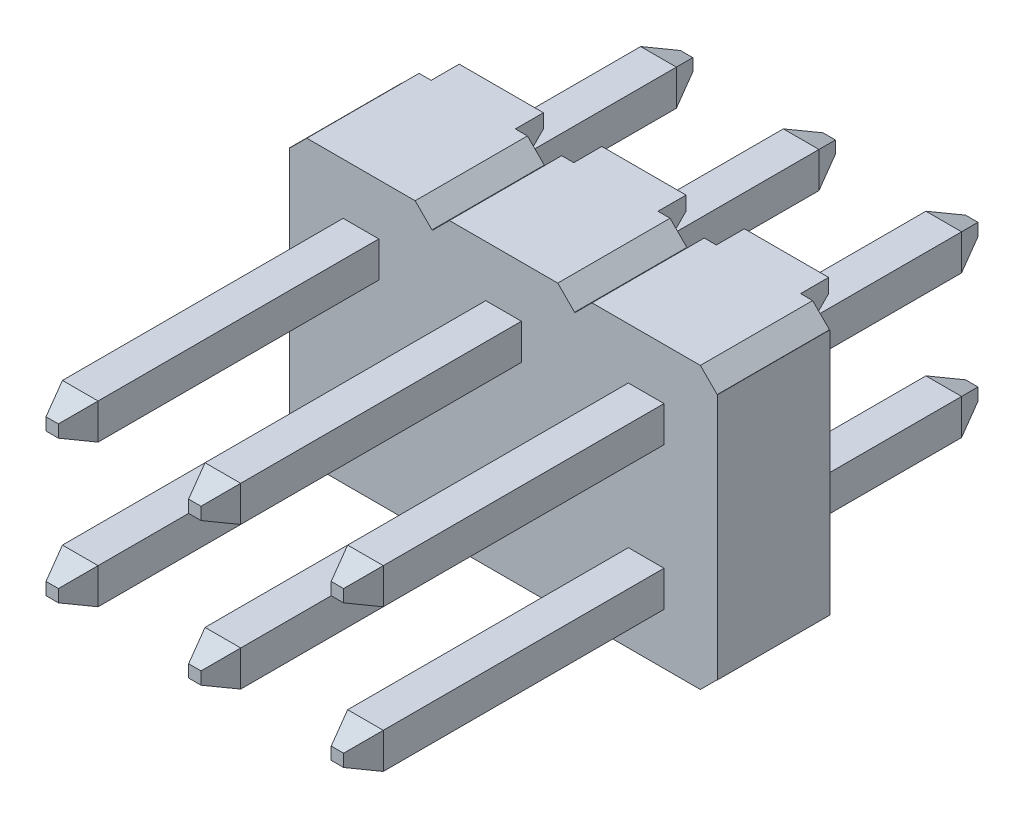
from build123d import *

# Parameters (mm, degrees)
SKETCH1_W              = 7.62
SKETCH1_H              = 5
BOSS_EXTRUDE1_DEPTH    = 2
SKETCH2_W              = 0.305
SKETCH2_H              = 0.3
CUT_EXTRUDE1_DEPTH     = 3
CUT_EXTRUDE2_DEPTH     = 3
CUT_EXTRUDE3_DEPTH     = 3
SKETCH5_W              = 0.305
SKETCH5_H              = 0.3
CUT_EXTRUDE4_DEPTH     = 2
SKETCH6_W              = 0.305
SKETCH6_H              = 0.3
CUT_EXTRUDE5_DEPTH     = 3
CUT_EXTRUDE6_DEPTH     = 3
CUT_EXTRUDE7_DEPTH     = 3
SKETCH9_W              = 0.305
SKETCH9_H              = 0.3
CUT_EXTRUDE8_DEPTH     = 2
SKETCH10_W             = 0.635
SKETCH10_H             = 0.635
BOSS_EXTRUDE2_DEPTH    = 3.8
SKETCH11_W             = 0.635
SKETCH11_H             = 0.635
BOSS_EXTRUDE3_DEPTH    = 3.8
SKETCH12_W             = 0.635
SKETCH12_H             = 0.635
BOSS_EXTRUDE4_DEPTH    = 3.8
SKETCH13_W             = 0.635
SKETCH13_H             = 0.635
BOSS_EXTRUDE5_DEPTH    = 3.8
SKETCH14_W             = 0.635
SKETCH14_H             = 0.635
BOSS_EXTRUDE6_DEPTH    = 3.8
SKETCH15_W             = 1.5
SKETCH15_H             = 0.75
BOSS_EXTRUDE7_DEPTH    = 0.5
SKETCH16_W             = 1.5
SKETCH16_H             = 0.75
BOSS_EXTRUDE8_DEPTH    = 0.5
SKETCH17_W             = 1.5
SKETCH17_H             = 0.75
BOSS_EXTRUDE9_DEPTH    = 0.5
SKETCH18_W             = 1.5
SKETCH18_H             = 0.75
BOSS_EXTRUDE10_DEPTH   = 0.5
SKETCH19_W             = 1.5
SKETCH19_H             = 0.75
BOSS_EXTRUDE11_DEPTH   = 0.5
SKETCH20_W             = 1.5
SKETCH20_H             = 0.75
BOSS_EXTRUDE12_DEPTH   = 0.5
SKETCH21_W             = 0.635
SKETCH21_H             = 0.635
BOSS_EXTRUDE13_DEPTH   = 3.8
SKETCH22_W             = 0.635
SKETCH22_H             = 0.635
BOSS_EXTRUDE14_DEPTH   = 5.5
SKETCH23_W             = 0.635
SKETCH23_H             = 0.635
BOSS_EXTRUDE15_DEPTH   = 5.5
SKETCH24_W             = 0.635
SKETCH24_H             = 0.635
BOSS_EXTRUDE16_DEPTH   = 5.5
SKETCH25_W             = 0.635
SKETCH25_H             = 0.635
BOSS_EXTRUDE17_DEPTH   = 5.5
SKETCH26_W             = 0.635
SKETCH26_H             = 0.635
BOSS_EXTRUDE18_DEPTH   = 5.5
SKETCH27_W             = 0.635
SKETCH27_H             = 0.635
BOSS_EXTRUDE19_DEPTH   = 5.5
DRAFT1_ANGLE           = 45
DRAFT2_ANGLE           = 45
DRAFT3_ANGLE           = 45
DRAFT4_ANGLE           = 45
DRAFT5_ANGLE           = 45
CHAMFER1_SIZE          = 0.007071068
CHAMFER2_SIZE          = 0.207106781
CHAMFER2_SIZE2         = 0.5
CHAMFER2_PART_2_SIZE   = 0.207106781
CHAMFER2_PART_2_SIZE2  = 0.5
CHAMFER2_PART_3_SIZE   = 0.207106781
CHAMFER2_PART_3_SIZE2  = 0.5
CHAMFER2_PART_4_SIZE   = 0.207106781
CHAMFER2_PART_4_SIZE2  = 0.5
CHAMFER2_PART_5_SIZE   = 0.207106781
CHAMFER2_PART_5_SIZE2  = 0.5
CHAMFER2_PART_6_SIZE   = 0.207106781
CHAMFER2_PART_6_SIZE2  = 0.5
CHAMFER2_PART_7_SIZE   = 0.207106781
CHAMFER2_PART_7_SIZE2  = 0.5
CHAMFER2_PART_8_SIZE   = 0.207106781
CHAMFER2_PART_8_SIZE2  = 0.5
CHAMFER2_PART_9_SIZE   = 0.207106781
CHAMFER2_PART_9_SIZE2  = 0.5
CHAMFER2_PART_10_SIZE  = 0.207106781
CHAMFER2_PART_10_SIZE2 = 0.5
CHAMFER2_PART_11_SIZE  = 0.207106781
CHAMFER2_PART_11_SIZE2 = 0.5
CHAMFER2_PART_12_SIZE  = 0.207106781
CHAMFER2_PART_12_SIZE2 = 0.5


with BuildPart() as part:
    # Sketch1 → Boss-Extrude1 (new body)
    with BuildSketch(Plane(origin=(0, 0, 0), x_dir=(-1, 0, 0), z_dir=(0, 0, -1))):
        with Locations((-3.81, 2.5)):
            Rectangle(SKETCH1_W, SKETCH1_H)
    extrude(amount=-BOSS_EXTRUDE1_DEPTH)

    # Sketch2 → Cut-Extrude1 (cut, through all)
    with BuildSketch(Plane.XY.offset(2)):
        with Locations((7.4675, 0.15)):
            Rectangle(SKETCH2_W, SKETCH2_H)
    extrude(amount=-CUT_EXTRUDE1_DEPTH, mode=Mode.SUBTRACT)

    # Sketch3 → Cut-Extrude2 (cut, through all)
    with BuildSketch(Plane.XY.offset(2)):
        Polygon((4.775, 0), (5.385, 0), (5.385, 0.61), align=None)
    extrude(amount=-CUT_EXTRUDE2_DEPTH, mode=Mode.SUBTRACT)

    # Sketch4 → Cut-Extrude3 (cut, through all)
    with BuildSketch(Plane.XY.offset(2)):
        Polygon((2.235, 0), (2.845, 0), (2.235, 0.61), align=None)
    extrude(amount=-CUT_EXTRUDE3_DEPTH, mode=Mode.SUBTRACT)

    # Sketch5 → Cut-Extrude4 (cut)
    with BuildSketch(Plane.XY.offset(2)):
        with Locations((0.1525, 0.15)):
            Rectangle(SKETCH5_W, SKETCH5_H)
    extrude(amount=-CUT_EXTRUDE4_DEPTH, mode=Mode.SUBTRACT)

    # Sketch6 → Cut-Extrude5 (cut, through all)
    with BuildSketch(Plane.XY.offset(2)):
        with Locations((0.1525, 4.85)):
            Rectangle(SKETCH6_W, SKETCH6_H)
    extrude(amount=-CUT_EXTRUDE5_DEPTH, mode=Mode.SUBTRACT)

    # Sketch7 → Cut-Extrude6 (cut, through all)
    with BuildSketch(Plane.XY.offset(2)):
        Polygon((2.845, 5), (2.235, 5), (2.235, 4.39), align=None)
    extrude(amount=-CUT_EXTRUDE6_DEPTH, mode=Mode.SUBTRACT)

    # Sketch8 → Cut-Extrude7 (cut, through all)
    with BuildSketch(Plane.XY.offset(2)):
        Polygon((5.385, 5), (4.775, 5), (5.385, 4.39), align=None)
    extrude(amount=-CUT_EXTRUDE7_DEPTH, mode=Mode.SUBTRACT)

    # Sketch9 → Cut-Extrude8 (cut)
    with BuildSketch(Plane.XY.offset(2)):
        with Locations((7.4675, 4.85)):
            Rectangle(SKETCH9_W, SKETCH9_H)
    extrude(amount=-CUT_EXTRUDE8_DEPTH, mode=Mode.SUBTRACT)

    # Sketch10 → Boss-Extrude2 (add)
    with BuildSketch(Plane(origin=(0, 0, 0), x_dir=(-1, 0, 0), z_dir=(0, 0, -1))):
        with Locations((-6.35, 3.77)):
            Rectangle(SKETCH10_W, SKETCH10_H)
    extrude(amount=BOSS_EXTRUDE2_DEPTH)

    # Sketch11 → Boss-Extrude3 (add)
    with BuildSketch(Plane(origin=(0, 0, 0), x_dir=(-1, 0, 0), z_dir=(0, 0, -1))):
        with Locations((-6.35, 1.23)):
            Rectangle(SKETCH11_W, SKETCH11_H)
    extrude(amount=BOSS_EXTRUDE3_DEPTH)

    # Sketch12 → Boss-Extrude4 (add)
    with BuildSketch(Plane(origin=(0, 0, 0), x_dir=(-1, 0, 0), z_dir=(0, 0, -1))):
        with Locations((-3.81, 3.77)):
            Rectangle(SKETCH12_W, SKETCH12_H)
    extrude(amount=BOSS_EXTRUDE4_DEPTH)

    # Sketch13 → Boss-Extrude5 (add)
    with BuildSketch(Plane(origin=(0, 0, 0), x_dir=(-1, 0, 0), z_dir=(0, 0, -1))):
        with Locations((-3.81, 1.23)):
            Rectangle(SKETCH13_W, SKETCH13_H)
    extrude(amount=BOSS_EXTRUDE5_DEPTH)

    # Sketch14 → Boss-Extrude6 (add)
    with BuildSketch(Plane(origin=(0, 0, 0), x_dir=(-1, 0, 0), z_dir=(0, 0, -1))):
        with Locations((-1.27, 3.77)):
            Rectangle(SKETCH14_W, SKETCH14_H)
    extrude(amount=BOSS_EXTRUDE6_DEPTH)

    # Sketch15 → Boss-Extrude7 (add)
    with BuildSketch(Plane(origin=(0, 0, 0), x_dir=(-1, 0, 0), z_dir=(0, 0, -1))):
        with Locations((-6.35, 0.375)):
            Rectangle(SKETCH15_W, SKETCH15_H)
    extrude(amount=BOSS_EXTRUDE7_DEPTH)

    # Sketch16 → Boss-Extrude8 (add)
    with BuildSketch(Plane(origin=(0, 0, 0), x_dir=(-1, 0, 0), z_dir=(0, 0, -1))):
        with Locations((-3.81, 0.375)):
            Rectangle(SKETCH16_W, SKETCH16_H)
    extrude(amount=BOSS_EXTRUDE8_DEPTH)

    # Sketch17 → Boss-Extrude9 (add)
    with BuildSketch(Plane(origin=(0, 0, 0), x_dir=(-1, 0, 0), z_dir=(0, 0, -1))):
        with Locations((-1.27, 0.375)):
            Rectangle(SKETCH17_W, SKETCH17_H)
    extrude(amount=BOSS_EXTRUDE9_DEPTH)

    # Sketch18 → Boss-Extrude10 (add)
    with BuildSketch(Plane(origin=(0, 0, 0), x_dir=(-1, 0, 0), z_dir=(0, 0, -1))):
        with Locations((-1.27, 4.625)):
            Rectangle(SKETCH18_W, SKETCH18_H)
    extrude(amount=BOSS_EXTRUDE10_DEPTH)

    # Sketch19 → Boss-Extrude11 (add)
    with BuildSketch(Plane(origin=(0, 0, 0), x_dir=(-1, 0, 0), z_dir=(0, 0, -1))):
        with Locations((-3.81, 4.625)):
            Rectangle(SKETCH19_W, SKETCH19_H)
    extrude(amount=BOSS_EXTRUDE11_DEPTH)

    # Sketch20 → Boss-Extrude12 (add)
    with BuildSketch(Plane(origin=(0, 0, 0), x_dir=(-1, 0, 0), z_dir=(0, 0, -1))):
        with Locations((-6.35, 4.625)):
            Rectangle(SKETCH20_W, SKETCH20_H)
    extrude(amount=BOSS_EXTRUDE12_DEPTH)

    # Sketch21 → Boss-Extrude13 (add)
    with BuildSketch(Plane(origin=(0, 0, 0), x_dir=(-1, 0, 0), z_dir=(0, 0, -1))):
        with Locations((-1.27, 1.23)):
            Rectangle(SKETCH21_W, SKETCH21_H)
    extrude(amount=BOSS_EXTRUDE13_DEPTH)

    # Sketch22 → Boss-Extrude14 (add)
    with BuildSketch(Plane.XY.offset(2)):
        with Locations((6.35, 3.77)):
            Rectangle(SKETCH22_W, SKETCH22_H)
    extrude(amount=BOSS_EXTRUDE14_DEPTH)

    # Sketch23 → Boss-Extrude15 (add)
    with BuildSketch(Plane.XY.offset(2)):
        with Locations((6.35, 1.23)):
            Rectangle(SKETCH23_W, SKETCH23_H)
    extrude(amount=BOSS_EXTRUDE15_DEPTH)

    # Sketch24 → Boss-Extrude16 (add)
    with BuildSketch(Plane.XY.offset(2)):
        with Locations((3.81, 3.77)):
            Rectangle(SKETCH24_W, SKETCH24_H)
    extrude(amount=BOSS_EXTRUDE16_DEPTH)

    # Sketch25 → Boss-Extrude17 (add)
    with BuildSketch(Plane.XY.offset(2)):
        with Locations((3.81, 1.23)):
            Rectangle(SKETCH25_W, SKETCH25_H)
    extrude(amount=BOSS_EXTRUDE17_DEPTH)

    # Sketch26 → Boss-Extrude18 (add)
    with BuildSketch(Plane.XY.offset(2)):
        with Locations((1.27, 3.77)):
            Rectangle(SKETCH26_W, SKETCH26_H)
    extrude(amount=BOSS_EXTRUDE18_DEPTH)

    # Sketch27 → Boss-Extrude19 (add)
    with BuildSketch(Plane.XY.offset(2)):
        with Locations((1.27, 1.23)):
            Rectangle(SKETCH27_W, SKETCH27_H)
    extrude(amount=BOSS_EXTRUDE19_DEPTH)

    # Draft1
    draft1_faces = [part.faces().sort_by_distance(p)[0] for p in [
        (5.385, 0.305, 1),
        (7.315, 0.15, 1),
    ]]
    draft(draft1_faces, Plane(origin=(7.62, 0, 2), x_dir=(0, 0, -1), z_dir=(0, -1, 0)), DRAFT1_ANGLE)

    # Draft2
    draft2_faces = [part.faces().sort_by_distance(p)[0] for p in [
        (0.305, 0.15, 1),
        (2.235, 0.305, 1),
    ]]
    draft(draft2_faces, Plane(origin=(7.62, 0, 2), x_dir=(0, 0, -1), z_dir=(0, -1, 0)), DRAFT2_ANGLE)

    # Draft3
    draft3_faces = [part.faces().sort_by_distance(p)[0] for p in [
        (2.235, 4.695, 1),
        (0.305, 4.85, 1),
    ]]
    draft(draft3_faces, Plane(origin=(0, 5, 2), x_dir=(0, 0, 1), z_dir=(0, 1, 0)), DRAFT3_ANGLE)

    # Draft4
    draft4_faces = [part.faces().sort_by_distance(p)[0] for p in [
        (7.315, 4.85, 1),
        (5.385, 4.695, 1),
    ]]
    draft(draft4_faces, Plane(origin=(0, 5, 2), x_dir=(0, 0, 1), z_dir=(0, 1, 0)), DRAFT4_ANGLE)

    # Draft5
    draft5_faces = [part.faces().sort_by_distance(p)[0] for p in [
        (6.35, 0.75, -0.25),
        (3.81, 0.75, -0.25),
        (1.27, 0.75, -0.25),
        (1.27, 4.25, -0.25),
        (3.81, 4.25, -0.25),
        (6.35, 4.25, -0.25),
    ]]
    draft(draft5_faces, Plane(origin=(0, 0, 0), x_dir=(-1, 0, 0), z_dir=(0, 0, -1)), DRAFT5_ANGLE)

    # Chamfer1
    chamfer1_edges = [part.edges().sort_by_distance(p)[0] for p in [
        (5.08, 4.695, 1),
        (5.08, 0.305, 1),
        (2.54, 0.305, 1),
        (2.54, 4.695, 1),
    ]]
    chamfer(chamfer1_edges, length=CHAMFER1_SIZE)

    # Chamfer2
    chamfer2_edges = [part.edges().sort_by_distance(p)[0] for p in [
        (6.6675, 3.77, -3.8),
        (6.35, 3.4525, -3.8),
        (6.0325, 3.77, -3.8),
        (6.35, 4.0875, -3.8),
    ]]
    chamfer2_side = [part.faces().sort_by_distance(p)[0] for p in [
        (6.35, 3.77, -3.8),
    ]]
    chamfer(chamfer2_edges, length=CHAMFER2_SIZE, length2=CHAMFER2_SIZE2, reference=chamfer2_side[0])

    # Chamfer2 part 2
    chamfer2_part_2_edges = [part.edges().sort_by_distance(p)[0] for p in [
        (6.35, 0.9125, -3.8),
        (6.0325, 1.23, -3.8),
        (6.35, 1.5475, -3.8),
        (6.6675, 1.23, -3.8),
    ]]
    chamfer2_part_2_side = [part.faces().sort_by_distance(p)[0] for p in [
        (6.35, 1.23, -3.8),
    ]]
    chamfer(chamfer2_part_2_edges, length=CHAMFER2_PART_2_SIZE, length2=CHAMFER2_PART_2_SIZE2, reference=chamfer2_part_2_side[0])

    # Chamfer2 part 3
    chamfer2_part_3_edges = [part.edges().sort_by_distance(p)[0] for p in [
        (3.81, 3.4525, -3.8),
        (3.4925, 3.77, -3.8),
        (3.81, 4.0875, -3.8),
        (4.1275, 3.77, -3.8),
    ]]
    chamfer2_part_3_side = [part.faces().sort_by_distance(p)[0] for p in [
        (3.81, 3.77, -3.8),
    ]]
    chamfer(chamfer2_part_3_edges, length=CHAMFER2_PART_3_SIZE, length2=CHAMFER2_PART_3_SIZE2, reference=chamfer2_part_3_side[0])

    # Chamfer2 part 4
    chamfer2_part_4_edges = [part.edges().sort_by_distance(p)[0] for p in [
        (3.81, 0.9125, -3.8),
        (3.4925, 1.23, -3.8),
        (3.81, 1.5475, -3.8),
        (4.1275, 1.23, -3.8),
    ]]
    chamfer2_part_4_side = [part.faces().sort_by_distance(p)[0] for p in [
        (3.81, 1.23, -3.8),
    ]]
    chamfer(chamfer2_part_4_edges, length=CHAMFER2_PART_4_SIZE, length2=CHAMFER2_PART_4_SIZE2, reference=chamfer2_part_4_side[0])

    # Chamfer2 part 5
    chamfer2_part_5_edges = [part.edges().sort_by_distance(p)[0] for p in [
        (1.27, 4.0875, -3.8),
        (1.5875, 3.77, -3.8),
        (1.27, 3.4525, -3.8),
        (0.9525, 3.77, -3.8),
    ]]
    chamfer2_part_5_side = [part.faces().sort_by_distance(p)[0] for p in [
        (1.27, 3.77, -3.8),
    ]]
    chamfer(chamfer2_part_5_edges, length=CHAMFER2_PART_5_SIZE, length2=CHAMFER2_PART_5_SIZE2, reference=chamfer2_part_5_side[0])

    # Chamfer2 part 6
    chamfer2_part_6_edges = [part.edges().sort_by_distance(p)[0] for p in [
        (1.27, 0.9125, -3.8),
        (0.9525, 1.23, -3.8),
        (1.27, 1.5475, -3.8),
        (1.5875, 1.23, -3.8),
    ]]
    chamfer2_part_6_side = [part.faces().sort_by_distance(p)[0] for p in [
        (1.27, 1.23, -3.8),
    ]]
    chamfer(chamfer2_part_6_edges, length=CHAMFER2_PART_6_SIZE, length2=CHAMFER2_PART_6_SIZE2, reference=chamfer2_part_6_side[0])

    # Chamfer2 part 7
    chamfer2_part_7_edges = [part.edges().sort_by_distance(p)[0] for p in [
        (6.0325, 3.77, 7.5),
        (6.35, 3.4525, 7.5),
        (6.6675, 3.77, 7.5),
        (6.35, 4.0875, 7.5),
    ]]
    chamfer2_part_7_side = [part.faces().sort_by_distance(p)[0] for p in [
        (6.35, 3.77, 7.5),
    ]]
    chamfer(chamfer2_part_7_edges, length=CHAMFER2_PART_7_SIZE, length2=CHAMFER2_PART_7_SIZE2, reference=chamfer2_part_7_side[0])

    # Chamfer2 part 8
    chamfer2_part_8_edges = [part.edges().sort_by_distance(p)[0] for p in [
        (6.35, 0.9125, 7.5),
        (6.6675, 1.23, 7.5),
        (6.35, 1.5475, 7.5),
        (6.0325, 1.23, 7.5),
    ]]
    chamfer2_part_8_side = [part.faces().sort_by_distance(p)[0] for p in [
        (6.35, 1.23, 7.5),
    ]]
    chamfer(chamfer2_part_8_edges, length=CHAMFER2_PART_8_SIZE, length2=CHAMFER2_PART_8_SIZE2, reference=chamfer2_part_8_side[0])

    # Chamfer2 part 9
    chamfer2_part_9_edges = [part.edges().sort_by_distance(p)[0] for p in [
        (3.4925, 3.77, 7.5),
        (3.81, 3.4525, 7.5),
        (4.1275, 3.77, 7.5),
        (3.81, 4.0875, 7.5),
    ]]
    chamfer2_part_9_side = [part.faces().sort_by_distance(p)[0] for p in [
        (3.81, 3.77, 7.5),
    ]]
    chamfer(chamfer2_part_9_edges, length=CHAMFER2_PART_9_SIZE, length2=CHAMFER2_PART_9_SIZE2, reference=chamfer2_part_9_side[0])

    # Chamfer2 part 10
    chamfer2_part_10_edges = [part.edges().sort_by_distance(p)[0] for p in [
        (3.4925, 1.23, 7.5),
        (3.81, 0.9125, 7.5),
        (4.1275, 1.23, 7.5),
        (3.81, 1.5475, 7.5),
    ]]
    chamfer2_part_10_side = [part.faces().sort_by_distance(p)[0] for p in [
        (3.81, 1.23, 7.5),
    ]]
    chamfer(chamfer2_part_10_edges, length=CHAMFER2_PART_10_SIZE, length2=CHAMFER2_PART_10_SIZE2, reference=chamfer2_part_10_side[0])

    # Chamfer2 part 11
    chamfer2_part_11_edges = [part.edges().sort_by_distance(p)[0] for p in [
        (0.9525, 3.77, 7.5),
        (1.27, 3.4525, 7.5),
        (1.5875, 3.77, 7.5),
        (1.27, 4.0875, 7.5),
    ]]
    chamfer2_part_11_side = [part.faces().sort_by_distance(p)[0] for p in [
        (1.27, 3.77, 7.5),
    ]]
    chamfer(chamfer2_part_11_edges, length=CHAMFER2_PART_11_SIZE, length2=CHAMFER2_PART_11_SIZE2, reference=chamfer2_part_11_side[0])

    # Chamfer2 part 12
    chamfer2_part_12_edges = [part.edges().sort_by_distance(p)[0] for p in [
        (1.27, 0.9125, 7.5),
        (1.5875, 1.23, 7.5),
        (1.27, 1.5475, 7.5),
        (0.9525, 1.23, 7.5),
    ]]
    chamfer2_part_12_side = [part.faces().sort_by_distance(p)[0] for p in [
        (1.27, 1.23, 7.5),
    ]]
    chamfer(chamfer2_part_12_edges, length=CHAMFER2_PART_12_SIZE, length2=CHAMFER2_PART_12_SIZE2, reference=chamfer2_part_12_side[0])


solid = part.part
